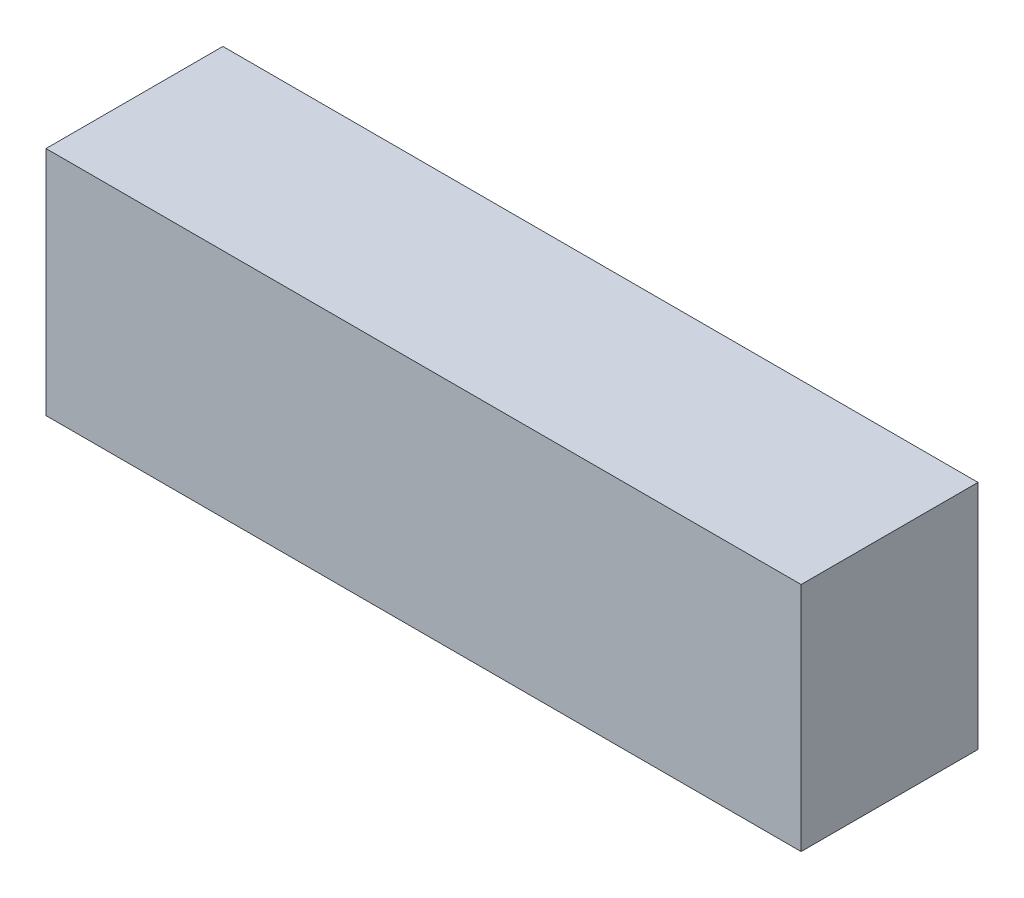
from build123d import *

# Parameters (mm, degrees)
CROQUIS1_W              = 111
CROQUIS1_H              = 34
SALIENTE_EXTRUIR1_DEPTH = 26


with BuildPart() as part:
    # Croquis1 → Saliente-Extruir1 (new body)
    with BuildSketch(Plane.XY):
        with Locations((55.5, 17)):
            Rectangle(CROQUIS1_W, CROQUIS1_H)
    extrude(amount=SALIENTE_EXTRUIR1_DEPTH)


solid = part.part
